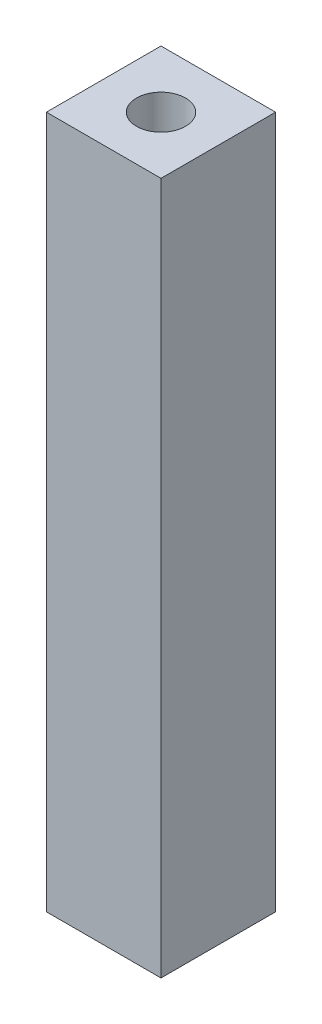
from build123d import *

# Parameters (mm, degrees)
CROQUIS1_W              = 9.1
CROQUIS1_H              = 9.1
SALIENTE_EXTRUIR1_DEPTH = 55
CROQUIS2_R              = 1.95
CORTAR_EXTRUIR1_DEPTH   = 13
CROQUIS3_R              = 1.95
CORTAR_EXTRUIR2_DEPTH   = 10


with BuildPart() as part:
    # Croquis1 → Saliente-Extruir1 (new body)
    with BuildSketch(Plane(origin=(0, 0, 0), x_dir=(1, 0, 0), z_dir=(0, 1, 0))):
        with Locations((4.55, 4.55)):
            Rectangle(CROQUIS1_W, CROQUIS1_H)
    extrude(amount=SALIENTE_EXTRUIR1_DEPTH)

    # Croquis2 → Cortar-Extruir1 (cut)
    with BuildSketch(Plane(origin=(0, 55, 0), x_dir=(1, 0, 0), z_dir=(0, 1, 0))):
        with Locations((4.55, 4.55)):
            Circle(CROQUIS2_R)
    extrude(amount=-CORTAR_EXTRUIR1_DEPTH, mode=Mode.SUBTRACT)

    # Croquis3 → Cortar-Extruir2 (cut)
    with BuildSketch(Plane.XZ):
        with Locations((4.55, -4.55)):
            Circle(CROQUIS3_R)
    extrude(amount=-CORTAR_EXTRUIR2_DEPTH, mode=Mode.SUBTRACT)


solid = part.part
